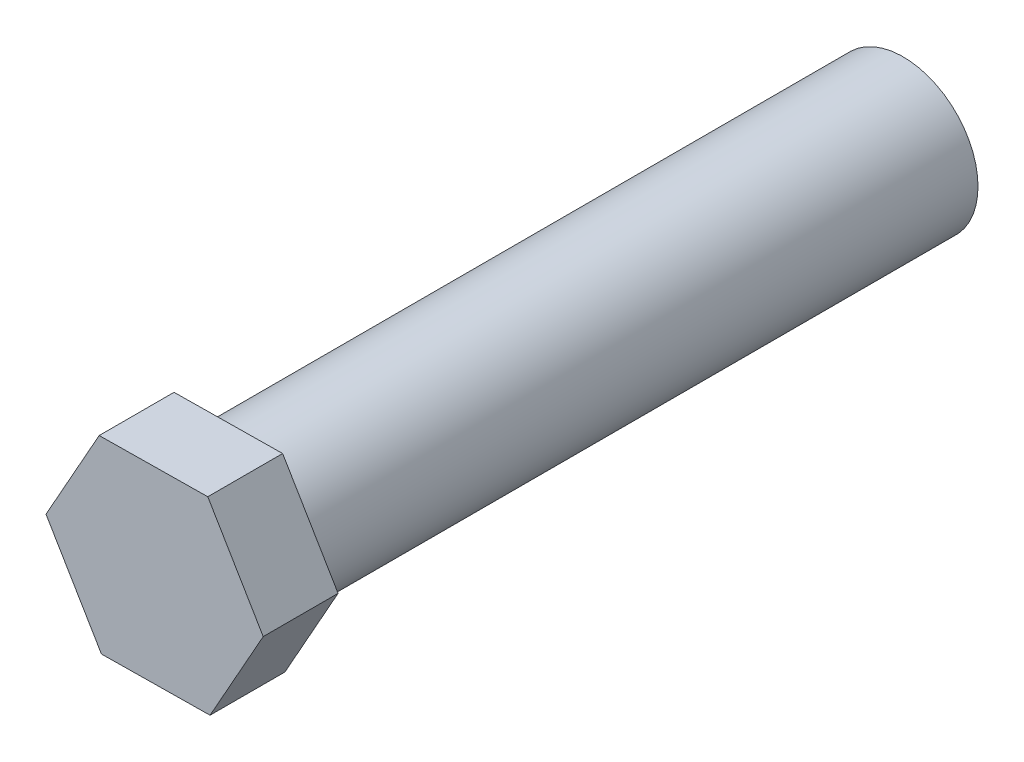
from build123d import *

# Parameters (mm, degrees)
SKETCH1_R           = 2
BOSS_EXTRUDE1_DEPTH = 18
BOSS_EXTRUDE2_DEPTH = 2


with BuildPart() as part:
    # Sketch1 → Boss-Extrude1 (new body)
    with BuildSketch(Plane.XY):
        Circle(SKETCH1_R)
    extrude(amount=BOSS_EXTRUDE1_DEPTH)

    # Sketch2 → Boss-Extrude2 (add)
    with BuildSketch(Plane.XY.offset(18)):
        Polygon((1.481135244, -2.495719019), (2.901923693, 0.034841238), (1.420788449, 2.530560257), (-1.481135244, 2.495719019), (-2.901923693, -0.034841238), (-1.420788449, -2.530560257), align=None)
    extrude(amount=BOSS_EXTRUDE2_DEPTH)


solid = part.part
